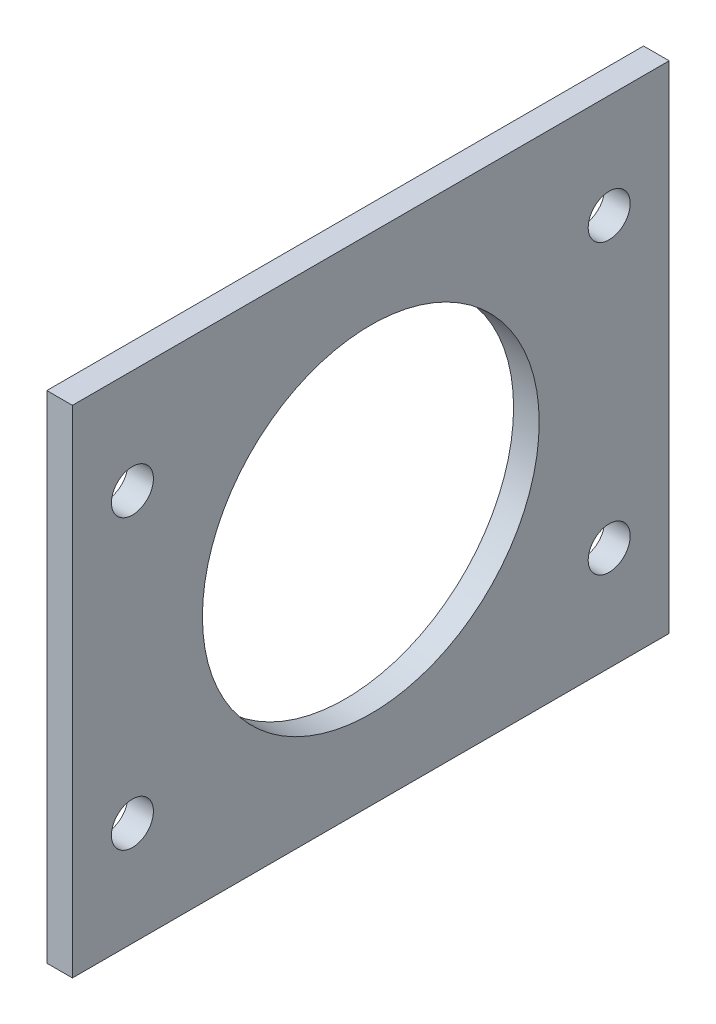
from build123d import *

# Parameters (mm, degrees)
SKETCH1_W           = 74.6
SKETCH1_H           = 62
BOSS_EXTRUDE1_DEPTH = 3.2
CUT_EXTRUDE1_REACH  = 5.2
SKETCH2_R           = 21.05
CUT_EXTRUDE2_REACH  = 5.2
SKETCH3_R           = 2.625


with BuildPart() as part:
    # Sketch1 → Boss-Extrude1 (new body)
    with BuildSketch(Plane(origin=(0, 0, 0), x_dir=(0, 0, -1), z_dir=(1, 0, 0))):
        with Locations((37.3, 31)):
            Rectangle(SKETCH1_W, SKETCH1_H)
    extrude(amount=BOSS_EXTRUDE1_DEPTH)

    # Sketch2 → Cut-Extrude1 (cut, up to next)
    with BuildSketch(Plane(origin=(3.2, 0, 0), x_dir=(0, 0, -1), z_dir=(1, 0, 0)), mode=Mode.PRIVATE) as cut_extrude1_sk1:
        with Locations((37.3, 31)):
            Circle(SKETCH2_R)
    cut_extrude1_tool1 = extrude(cut_extrude1_sk1.sketch, amount=-CUT_EXTRUDE1_REACH, mode=Mode.PRIVATE) & part.part
    add(cut_extrude1_tool1.solids().sort_by_distance((3.2, 31, -37.3))[0], mode=Mode.SUBTRACT)

    # Sketch3 → Cut-Extrude2 (cut, up to next)
    with BuildSketch(Plane.ZY, mode=Mode.PRIVATE) as cut_extrude2_sk1:
        with Locations((-67.1, 13)):
            Circle(SKETCH3_R)
    cut_extrude2_tool1 = extrude(cut_extrude2_sk1.sketch, amount=-CUT_EXTRUDE2_REACH, mode=Mode.PRIVATE) & part.part
    add(cut_extrude2_tool1.solids().sort_by_distance((0, 13, -67.1))[0], mode=Mode.SUBTRACT)
    # Sketch3 → Cut-Extrude2 (cut, up to next)
    with BuildSketch(Plane.ZY, mode=Mode.PRIVATE) as cut_extrude2_sk2:
        with Locations((-67.1, 49)):
            Circle(SKETCH3_R)
    cut_extrude2_tool2 = extrude(cut_extrude2_sk2.sketch, amount=-CUT_EXTRUDE2_REACH, mode=Mode.PRIVATE) & part.part
    add(cut_extrude2_tool2.solids().sort_by_distance((0, 49, -67.1))[0], mode=Mode.SUBTRACT)
    # Sketch3 → Cut-Extrude2 (cut, up to next)
    with BuildSketch(Plane.ZY, mode=Mode.PRIVATE) as cut_extrude2_sk3:
        with Locations((-7.5, 13)):
            Circle(SKETCH3_R)
    cut_extrude2_tool3 = extrude(cut_extrude2_sk3.sketch, amount=-CUT_EXTRUDE2_REACH, mode=Mode.PRIVATE) & part.part
    add(cut_extrude2_tool3.solids().sort_by_distance((0, 13, -7.5))[0], mode=Mode.SUBTRACT)
    # Sketch3 → Cut-Extrude2 (cut, up to next)
    with BuildSketch(Plane.ZY, mode=Mode.PRIVATE) as cut_extrude2_sk4:
        with Locations((-7.5, 49)):
            Circle(SKETCH3_R)
    cut_extrude2_tool4 = extrude(cut_extrude2_sk4.sketch, amount=-CUT_EXTRUDE2_REACH, mode=Mode.PRIVATE) & part.part
    add(cut_extrude2_tool4.solids().sort_by_distance((0, 49, -7.5))[0], mode=Mode.SUBTRACT)


solid = part.part
